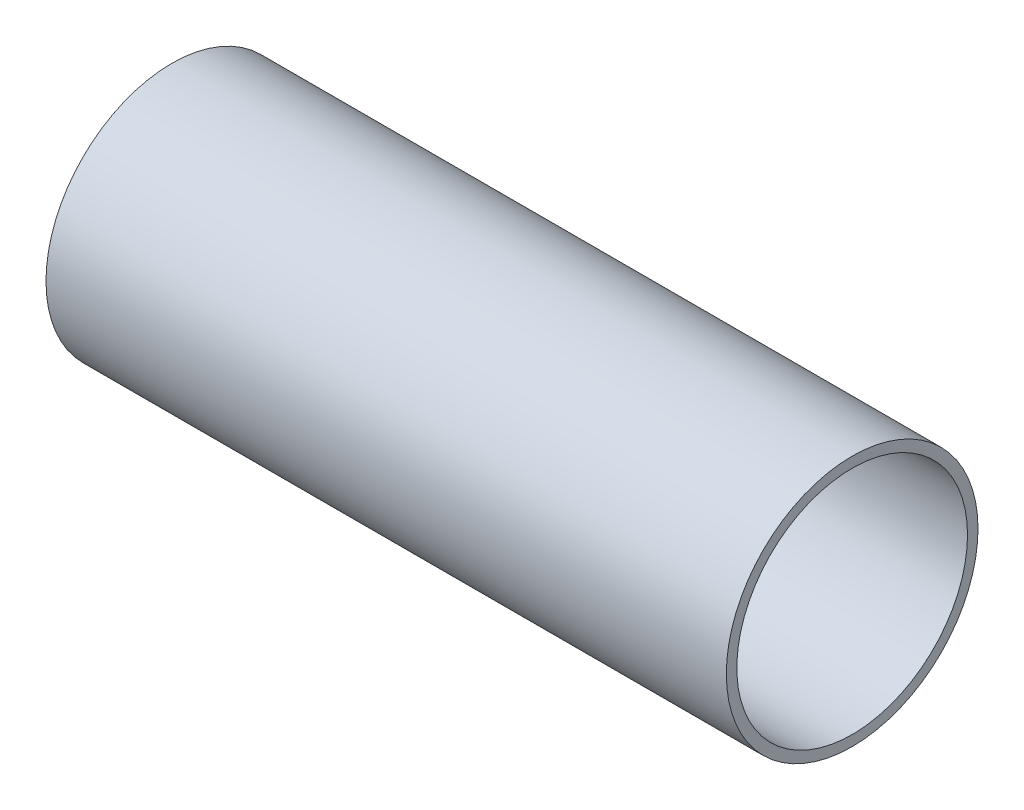
from build123d import *

# Parameters (mm, degrees)
SKETCH1_R           = 76.2
SKETCH1_R_2         = 69.85
BOSS_EXTRUDE1_DEPTH = 206


with BuildPart() as part:
    # Sketch1 → Boss-Extrude1 (new body, symmetric)
    with BuildSketch(Plane(origin=(0, 0, 0), x_dir=(0, 0, -1), z_dir=(1, 0, 0))):
        Circle(SKETCH1_R)
        Circle(SKETCH1_R_2, mode=Mode.SUBTRACT)
    extrude(amount=BOSS_EXTRUDE1_DEPTH, both=True)


solid = part.part
